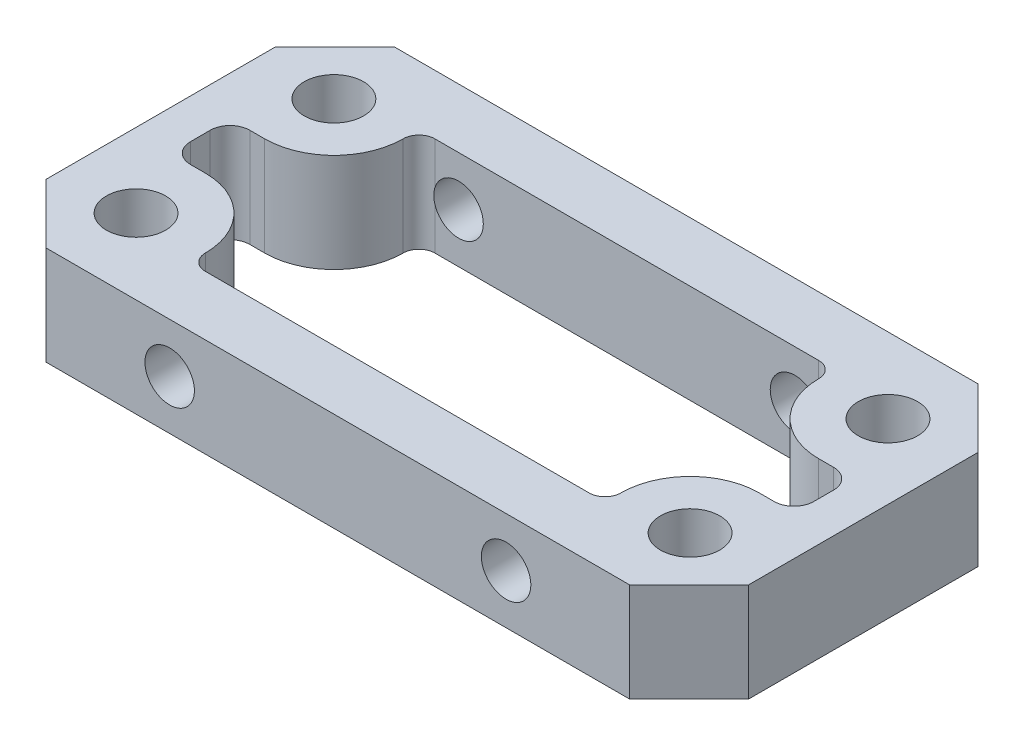
from build123d import *

# Parameters (mm, degrees)
SKETCH_1_W          = 35.5
SKETCH_1_H          = 17.6
SKETCH_1_R          = 1.5
EXTRUDE_1_DEPTH     = 38
CUT_EXTRUDE_1_DEPTH = 39
SKETCH_4_W          = 29.5
SKETCH_4_H          = 28
CUT_EXTRUDE_3_DEPTH = 18.6
SKETCH_5_W          = 35.5
SKETCH_5_H          = 33
CUT_EXTRUDE_4_DEPTH = 18.6
CHAMFER_1_SIZE      = 3
SKETCH_7_R          = 1.25
CUT_EXTRUDE_5_DEPTH = 18.6


with BuildPart() as part:
    # 草图1 → 凸台-拉伸1 (new body)
    with BuildSketch(Plane(origin=(0, 0, 0), x_dir=(1, 0, 0), z_dir=(0, 1, 0))):
        Rectangle(SKETCH_1_W, SKETCH_1_H)
        with Locations((-14, 5)):
            Circle(SKETCH_1_R, mode=Mode.SUBTRACT)
        with Locations((-14, -5)):
            Circle(SKETCH_1_R, mode=Mode.SUBTRACT)
        with Locations((14, -5)):
            Circle(SKETCH_1_R, mode=Mode.SUBTRACT)
        with Locations((14, 5)):
            Circle(SKETCH_1_R, mode=Mode.SUBTRACT)
    extrude(amount=EXTRUDE_1_DEPTH)

    # 草图2 → 切除-拉伸1 (cut, through all)
    with BuildSketch(Plane(origin=(0, 38, 0), x_dir=(1, 0, 0), z_dir=(0, 1, 0))):
        with BuildLine():
            Line((9.7, 5.8), (-9.7, 5.8))
            ThreePointArc((-9.7, 5.8), (-10.265685425, 5.565685425), (-10.5, 5))
            ThreePointArc((-10.5, 5), (-11.525126266, 2.525126266), (-14, 1.5))
            Line((-14, 1.5), (-14.75, 1.5))
            ThreePointArc((-14.75, 1.5), (-15.457106781, 1.207106781), (-15.75, 0.5))
            Line((-15.75, 0.5), (-15.75, -0.5))
            ThreePointArc((-15.75, -0.5), (-15.457106781, -1.207106781), (-14.75, -1.5))
            Line((-14.75, -1.5), (-14, -1.5))
            ThreePointArc((-14, -1.5), (-11.525126266, -2.525126266), (-10.5, -5))
            ThreePointArc((-10.5, -5), (-10.265685425, -5.565685425), (-9.7, -5.8))
            Line((-9.7, -5.8), (9.7, -5.8))
            ThreePointArc((9.7, -5.8), (10.265685425, -5.565685425), (10.5, -5))
            ThreePointArc((10.5, -5), (11.525126266, -2.525126266), (14, -1.5))
            Line((14, -1.5), (14.75, -1.5))
            ThreePointArc((14.75, -1.5), (15.457106781, -1.207106781), (15.75, -0.5))
            Line((15.75, -0.5), (15.75, 0.5))
            ThreePointArc((15.75, 0.5), (15.457106781, 1.207106781), (14.75, 1.5))
            Line((14.75, 1.5), (14, 1.5))
            ThreePointArc((14, 1.5), (11.525126266, 2.525126266), (10.5, 5))
            ThreePointArc((10.5, 5), (10.265685425, 5.565685425), (9.7, 5.8))
        make_face()
    extrude(amount=-CUT_EXTRUDE_1_DEPTH, mode=Mode.SUBTRACT)

    # 草图4 → 切除-拉伸3 (cut, through all)
    with BuildSketch(Plane.XY.offset(8.8)):
        with Locations((0, 19)):
            Rectangle(SKETCH_4_W, SKETCH_4_H)
    extrude(amount=-CUT_EXTRUDE_3_DEPTH, mode=Mode.SUBTRACT)

    # 草图5 → 切除-拉伸4 (cut, through all)
    with BuildSketch(Plane.XY.offset(8.8)):
        with Locations((0, 16.5)):
            Rectangle(SKETCH_5_W, SKETCH_5_H)
    extrude(amount=-CUT_EXTRUDE_4_DEPTH, mode=Mode.SUBTRACT)

    # 倒角1
    chamfer_1_edges = [part.edges().sort_by_distance(p)[0] for p in [
        (17.75, 35.5, 8.8),
        (-17.75, 35.5, 8.8),
        (-17.75, 35.5, -8.8),
        (17.75, 35.5, -8.8),
    ]]
    chamfer(chamfer_1_edges, length=CHAMFER_1_SIZE)

    # 草图7 → 切除-拉伸5 (cut, through all)
    with BuildSketch(Plane(origin=(0, 0, -8.8), x_dir=(-1, 0, 0), z_dir=(0, 0, -1))):
        with Locations((-8.5, 35.5)):
            Circle(SKETCH_7_R)
        with Locations((8.5, 35.5)):
            Circle(SKETCH_7_R)
    extrude(amount=-CUT_EXTRUDE_5_DEPTH, mode=Mode.SUBTRACT)


solid = part.part
